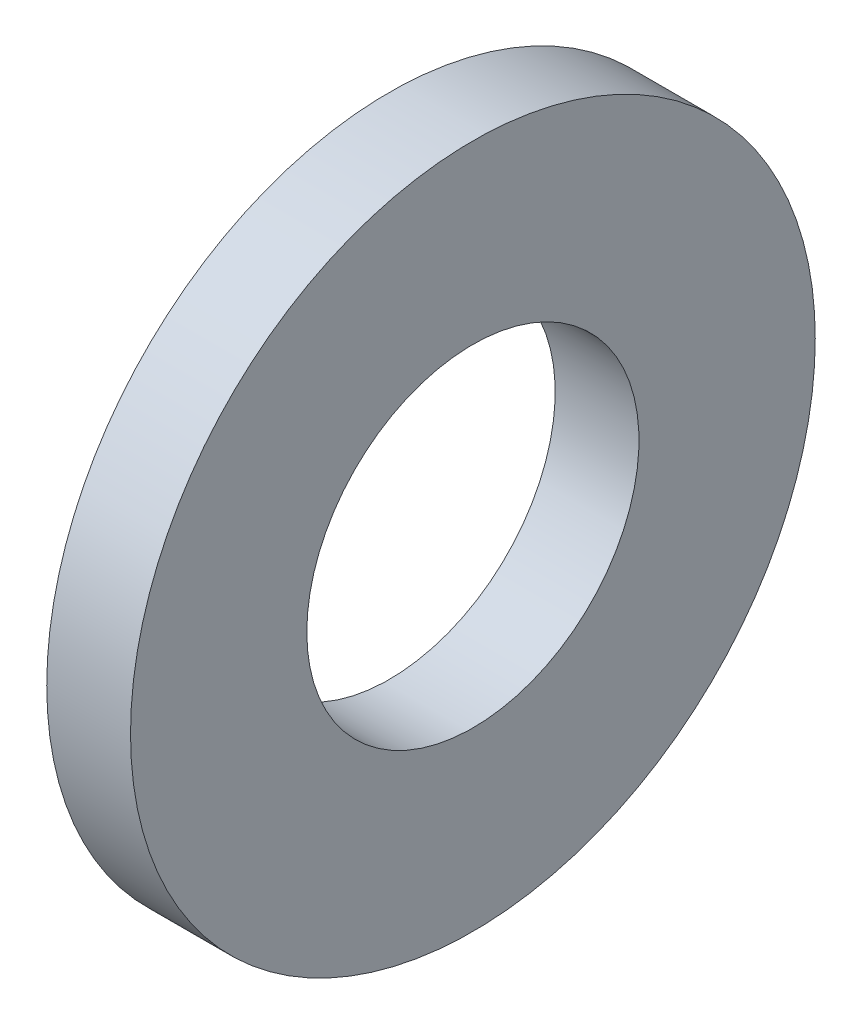
from build123d import *

# Parameters (mm, degrees)
SKETCH1_W = 2.3
SKETCH1_H = 4.84


with BuildPart() as part:
    # Sketch1 → Base-Revolve (revolve)
    with BuildSketch(Plane.XY):
        with Locations((-1.15, 6.98)):
            Rectangle(SKETCH1_W, SKETCH1_H)
    revolve(axis=Axis((-34.925, 0, 0), (1, 0, 0)))


solid = part.part
